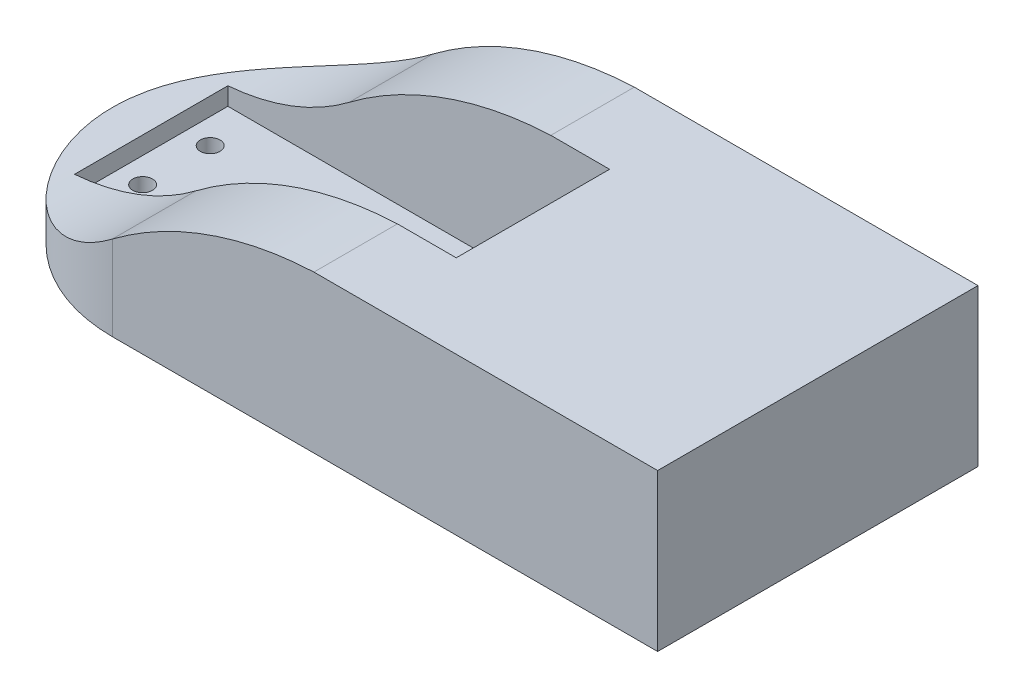
from build123d import *

# Parameters (mm, degrees)
SKETCH1_R               = 23.5
SKETCH1_W               = 80
SKETCH1_H               = 47
BOSS_EXTRUDE1_DEPTH     = 23
SKETCH3_W               = 56
SKETCH3_H               = 22.5
CUT_EXTRUDE1_DEPTH      = 20
CUT_EXTRUDE2_DEPTH      = 48
M3_5X0_6_TAPPED_HOLE1_D = 2.9


with BuildPart() as part:
    # Sketch1 → Boss-Extrude1 (new body)
    with BuildSketch(Plane(origin=(0, 0, 0), x_dir=(1, 0, 0), z_dir=(0, 1, 0))):
        Circle(SKETCH1_R)
        with Locations((40, 0)):
            Rectangle(SKETCH1_W, SKETCH1_H)
    extrude(amount=BOSS_EXTRUDE1_DEPTH)

    # Sketch3 → Cut-Extrude1 (cut)
    with BuildSketch(Plane(origin=(0, 23, 0), x_dir=(1, 0, 0), z_dir=(0, 1, 0))):
        with Locations((10.2, 0)):
            Rectangle(SKETCH3_W, SKETCH3_H)
    extrude(amount=-CUT_EXTRUDE1_DEPTH, mode=Mode.SUBTRACT)

    # Sketch4 → Cut-Extrude2 (cut, through all)
    with BuildSketch(Plane.XY.offset(23.5)):
        with BuildLine():
            Line((0, 23), (29.574214856, 23))
            ThreePointArc((29.574214856, 23), (13.980947767, 19.955758133), (0, 12.409203517))
            ThreePointArc((0, 12.409203517), (-11.118700592, 6.831963759), (-23.5, 5.634244617))
            Line((-23.5, 5.634244617), (-23.5, 23))
            Line((-23.5, 23), (0, 23))
        make_face()
    extrude(amount=-CUT_EXTRUDE2_DEPTH, mode=Mode.SUBTRACT)

    # M3.5x0.6 Tapped Hole1 (through all)
    with Locations(Plane(origin=(0, 3, 0), x_dir=(1, 0, 0), z_dir=(0, 1, 0))):
        with Locations((-14.100375238, 4.953237367), (-14.100375238, -4.956255047), (34.5, -4.95), (34.5, 4.953237367)):
            Hole(M3_5X0_6_TAPPED_HOLE1_D / 2)


solid = part.part
